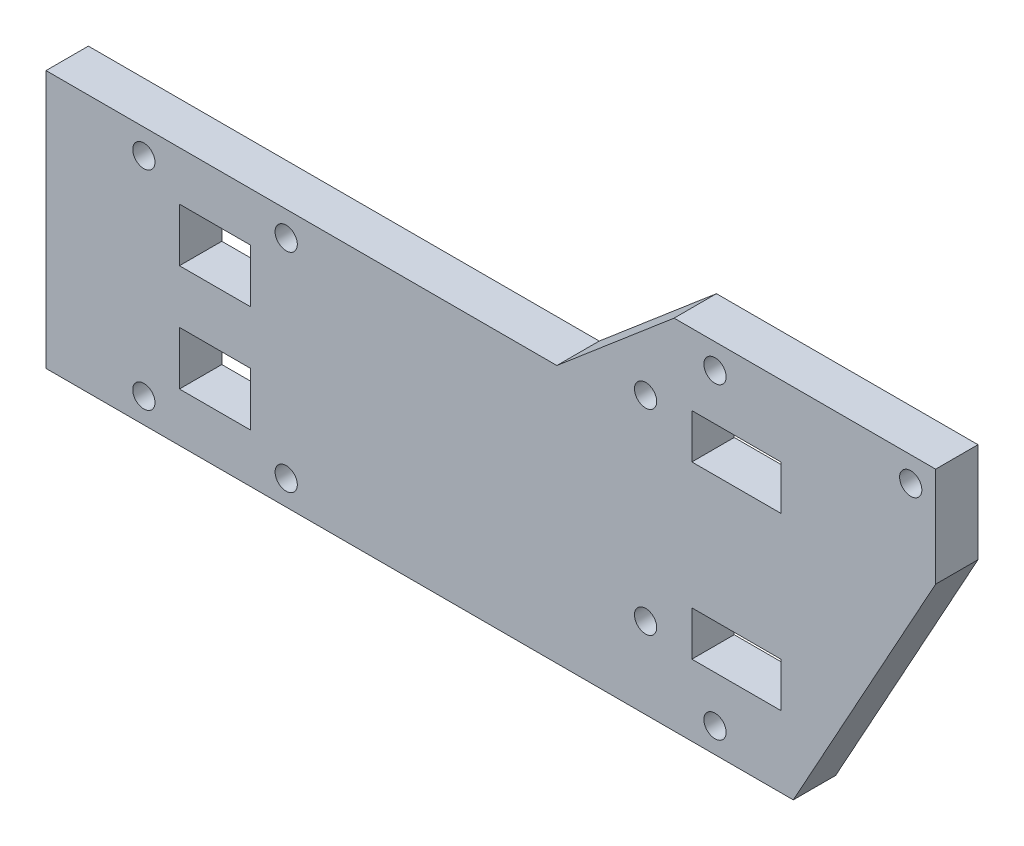
from build123d import *

# Parameters (mm, degrees)
BOSS_EXTRUDE1_DEPTH = 4.7625
SKETCH2_R           = 1.25
SKETCH2_W           = 10
SKETCH2_H           = 5
SKETCH2_W_2         = 8
SKETCH2_H_2         = 6
CUT_EXTRUDE1_DEPTH  = 5.7625


with BuildPart() as part:
    # Sketch1 → Boss-Extrude1 (new body)
    with BuildSketch(Plane.XY):
        Polygon((70.6, 40.2), (57.423529412, 29), (0, 29), (0, 0), (84, 0), (100, 29), (100, 40.2), align=None)
    extrude(amount=BOSS_EXTRUDE1_DEPTH)

    # Sketch2 → Cut-Extrude1 (cut, through all)
    with BuildSketch(Plane.XY.offset(4.7625)):
        with Locations((97.2, 37.4)):
            Circle(SKETCH2_R)
        with Locations((75.2, 37.4)):
            Circle(SKETCH2_R)
        with Locations((67.4, 31.1)):
            Circle(SKETCH2_R)
        with Locations((67.4, 9.1)):
            Circle(SKETCH2_R)
        with Locations((75.2, 2.8)):
            Circle(SKETCH2_R)
        with Locations((11, 26.2)):
            Circle(SKETCH2_R)
        with Locations((27, 26.2)):
            Circle(SKETCH2_R)
        with Locations((27, 2.8)):
            Circle(SKETCH2_R)
        with Locations((11, 2.8)):
            Circle(SKETCH2_R)
        with Locations((77.6, 29.7)):
            Rectangle(SKETCH2_W, SKETCH2_H)
        with Locations((77.6, 10.5)):
            Rectangle(SKETCH2_W, SKETCH2_H)
        with Locations((19, 20.5)):
            Rectangle(SKETCH2_W_2, SKETCH2_H_2)
        with Locations((19, 8.5)):
            Rectangle(SKETCH2_W_2, SKETCH2_H_2)
    extrude(amount=-CUT_EXTRUDE1_DEPTH, mode=Mode.SUBTRACT)


solid = part.part
